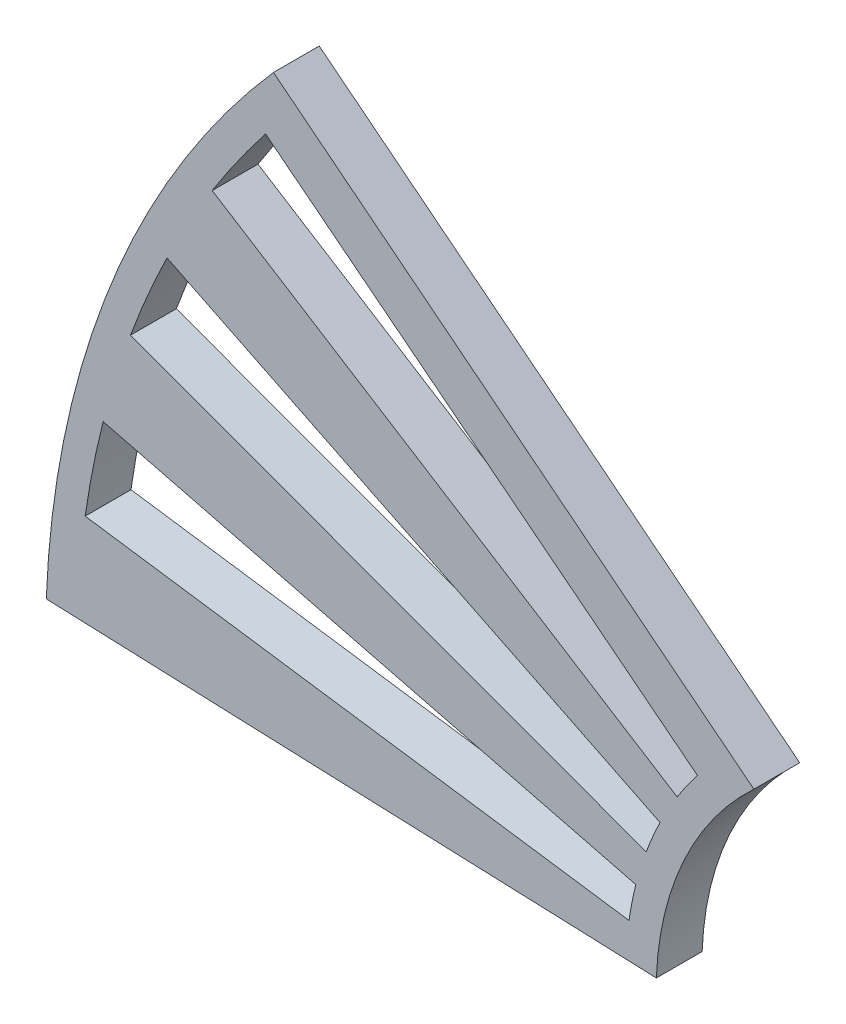
from build123d import *

# Parameters (mm, degrees)
BOSS_EXTRUDE2_DEPTH = 3
CUT_EXTRUDE1_REACH  = 5


with BuildPart() as part:
    # Sketch1 → Boss-Extrude2 (new body)
    with BuildSketch(Plane.XY):
        with BuildLine():
            Line((-19.985447982, 0.762803358), (-59.956343946, 2.288410074))
            ThreePointArc((-59.956343946, 2.288410074), (-55.730717245, 22.228071336), (-45.073672701, 39.602576043))
            Line((-45.073672701, 39.602576043), (-13.592462366, 14.67122922))
            ThreePointArc((-13.592462366, 14.67122922), (-18.172234131, 8.352838241), (-19.985447982, 0.762803358))
        make_face()
    extrude(amount=BOSS_EXTRUDE2_DEPTH)

    # Sketch2 → Cut-Extrude1 (cut, up to next)
    with BuildSketch(Plane.XY.offset(3), mode=Mode.PRIVATE) as cut_extrude1_sk1:
        with BuildLine():
            Line((-45.58858723, 35.856390146), (-17.292222743, 13.600699711))
            ThreePointArc((-17.292222743, 13.600699711), (-17.980329977, 12.677055412), (-18.619154377, 11.718664185))
            Line((-18.619154377, 11.718664185), (-49.08686154, 30.894660124))
            ThreePointArc((-49.08686154, 30.894660124), (-47.402688122, 33.421327903), (-45.58858723, 35.856390146))
        make_face()
    cut_extrude1_tool1 = extrude(cut_extrude1_sk1.sketch, amount=-CUT_EXTRUDE1_REACH, mode=Mode.PRIVATE) & part.part
    add(cut_extrude1_tool1.solids().sort_by_distance((-34.882242, 24.593771, 3))[0], mode=Mode.SUBTRACT)
    # Sketch2 → Cut-Extrude1 (cut, up to next)
    with BuildSketch(Plane.XY.offset(3), mode=Mode.PRIVATE) as cut_extrude1_sk2:
        with BuildLine():
            Line((-52.047329922, 25.59444174), (-19.74209066, 9.708236522))
            ThreePointArc((-19.74209066, 9.708236522), (-20.223124653, 8.661710528), (-20.648728467, 7.591443388))
            Line((-20.648728467, 7.591443388), (-54.437556866, 20.013805296))
            ThreePointArc((-54.437556866, 20.013805296), (-53.315510448, 22.835418665), (-52.047329922, 25.59444174))
        make_face()
    cut_extrude1_tool2 = extrude(cut_extrude1_sk2.sketch, amount=-CUT_EXTRUDE1_REACH, mode=Mode.PRIVATE) & part.part
    add(cut_extrude1_tool2.solids().sort_by_distance((-39.233314, 16.803912, 3))[0], mode=Mode.SUBTRACT)
    # Sketch2 → Cut-Extrude1 (cut, up to next)
    with BuildSketch(Plane.XY.offset(3), mode=Mode.PRIVATE) as cut_extrude1_sk3:
        with BuildLine():
            Line((-56.231354546, 14.213893413), (-21.329134483, 5.391476812))
            ThreePointArc((-21.329134483, 5.391476812), (-21.58207174, 4.267807331), (-21.775854038, 3.132440087))
            Line((-21.775854038, 3.132440087), (-57.409069737, 8.25825114))
            ThreePointArc((-57.409069737, 8.25825114), (-56.898189132, 11.251492055), (-56.231354546, 14.213893413))
        make_face()
    cut_extrude1_tool3 = extrude(cut_extrude1_sk3.sketch, amount=-CUT_EXTRUDE1_REACH, mode=Mode.PRIVATE) & part.part
    add(cut_extrude1_tool3.solids().sort_by_distance((-41.869702, 8.279642, 3))[0], mode=Mode.SUBTRACT)


solid = part.part
